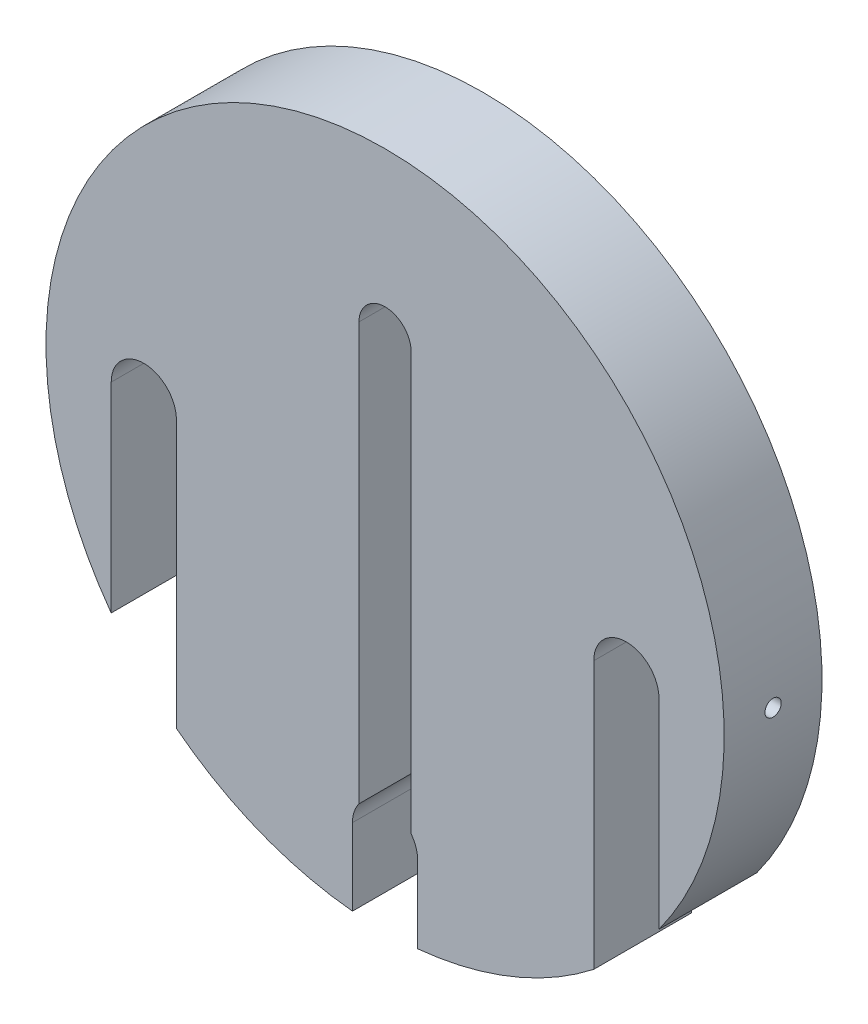
from build123d import *

# Parameters (mm, degrees)
SKETCH1_R              = 52
BOSS_EXTRUDE1_DEPTH    = 15
CUT_EXTRUDE1_DEPTH     = 15
CUT_EXTRUDE2_DEPTH     = 30
M3_TAPPED_HOLE1_REACH  = 119.239
M3_TAPPED_HOLE1_BORE_R = 1.25


with BuildPart() as part:
    # Sketch1 → Boss-Extrude1 (new body)
    with BuildSketch(Plane.XY):
        Circle(SKETCH1_R)
    extrude(amount=BOSS_EXTRUDE1_DEPTH)

    # Sketch2 → Cut-Extrude1 (cut)
    with BuildSketch(Plane.XY.offset(15)):
        with BuildLine():
            Line((32, 0), (32, -45))
            Line((32, -45), (42, -45))
            Line((42, -45), (42, 3.54e-07))
            ThreePointArc((42, 3.54e-07), (36.999999823, 5), (32, 0))
        make_face()
        with BuildLine():
            Line((-5, -39.999999646), (-5, -55))
            Line((-5, -55), (5, -55))
            Line((5, -55), (5, -40))
            ThreePointArc((5, -40), (1.77e-07, -35), (-5, -39.999999646))
        make_face()
        with BuildLine():
            Line((-32, -45), (-42, -45))
            Line((-42, -45), (-42, 3.54e-07))
            ThreePointArc((-42, 3.54e-07), (-36.999999823, 5), (-32, 0))
            Line((-32, 0), (-32, -45))
        make_face()
    extrude(amount=-CUT_EXTRUDE1_DEPTH, mode=Mode.SUBTRACT)

    # Sketch3 → Cut-Extrude2 (cut)
    with BuildSketch(Plane.XY.offset(15)):
        with BuildLine():
            Line((4, 27.000000608), (4, -40))
            Line((4, -40), (-4, -40))
            Line((-4, -40), (-4, 27))
            ThreePointArc((-4, 27), (-3.04e-07, 31), (4, 27.000000608))
        make_face()
    extrude(amount=-CUT_EXTRUDE2_DEPTH, mode=Mode.SUBTRACT)

    # M3 Tapped Hole1 bore → M3 Tapped Hole1 (cut, up to next)
    with BuildSketch(Plane.ZY.offset(52), mode=Mode.PRIVATE) as m3_tapped_hole1_sk1:
        with Locations((7.5, 4.2e-08)):
            Circle(M3_TAPPED_HOLE1_BORE_R)
    m3_tapped_hole1_tool1 = extrude(m3_tapped_hole1_sk1.sketch, amount=-M3_TAPPED_HOLE1_REACH, mode=Mode.PRIVATE) & part.part
    m3_tapped_hole1 = m3_tapped_hole1_tool1.solids().sort_by_distance((-52, 0, 7.5))[0]
    add(m3_tapped_hole1, mode=Mode.SUBTRACT)

    # Mirror1: M3 Tapped Hole1 across plane
    add(m3_tapped_hole1.mirror(Plane(origin=(0, 0, 0), x_dir=(0, 0, 1), z_dir=(1, 0, 0))), mode=Mode.SUBTRACT)


solid = part.part
